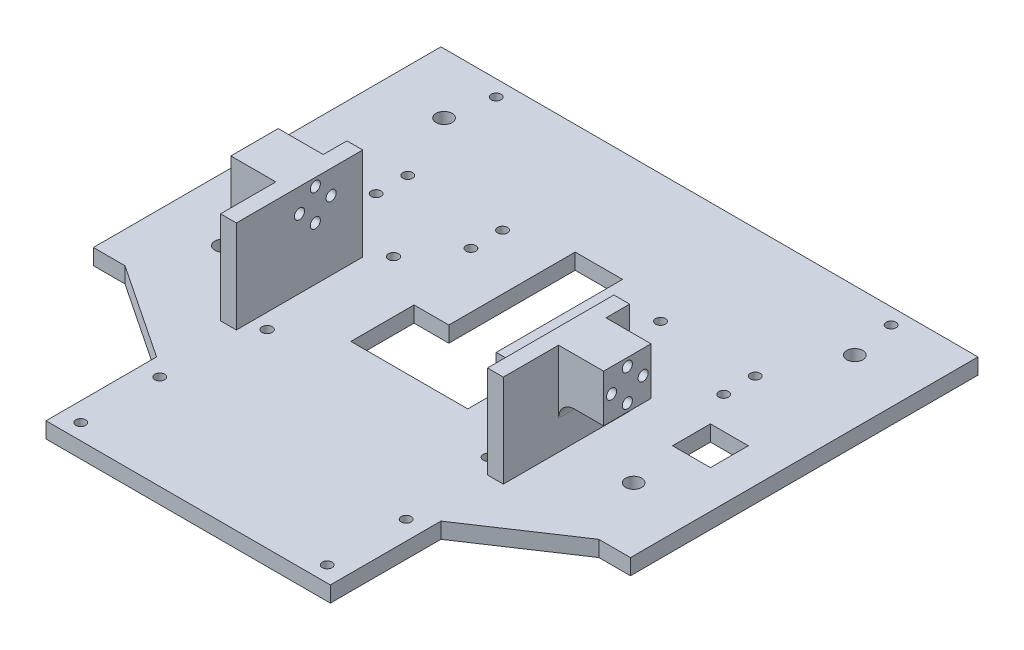
from build123d import *

# Parameters (mm, degrees)
BOSS_EXTRUDE1_DEPTH     = 5
CUT_EXTRUDE1_DEPTH      = 114.468057179
CUT_EXTRUDE1_DEPTH_BACK = 114.468057179
SKETCH3_R               = 1.6
SKETCH4_R               = 2.55
CUT_EXTRUDE2_DEPTH      = 10
SKETCH5_R               = 1.55
CUT_EXTRUDE3_DEPTH      = 114.468057179
SKETCH6_R               = 1.55
CUT_EXTRUDE4_DEPTH      = 114.468057179
SKETCH7_W               = 23
SKETCH7_H               = 110
BOSS_EXTRUDE2_DEPTH     = 5
SKETCH9_W               = 5
SKETCH9_H               = 40
BOSS_EXTRUDE4_DEPTH     = 33
SKETCH11_W              = 12
SKETCH11_H              = 12
CUT_EXTRUDE5_DEPTH      = 50
SKETCH12_R              = 1.6
CUT_EXTRUDE6_DEPTH      = 50
BOSS_EXTRUDE5_START     = 14.25
SKETCH13_W              = 15
SKETCH13_H              = 15
SKETCH13_R              = 1.6
BOSS_EXTRUDE5_DEPTH     = 14.25
SKETCH15_W              = 89.5
SKETCH15_H              = 3.65
CUT_EXTRUDE9_DEPTH      = 153.144667997
SKETCH18_W              = 13
SKETCH18_H              = 110
CUT_EXTRUDE10_DEPTH     = 134.005347637
FILLET5_R               = 5
SKETCH19_R              = 1.55
CUT_EXTRUDE11_DEPTH     = 5


with BuildPart() as part:
    # Sketch1 → Boss-Extrude1 (new body)
    with BuildSketch(Plane(origin=(0, 0, 0), x_dir=(1, 0, 0), z_dir=(0, 1, 0))):
        Polygon((75, 85), (-75, 85), (-75, -25), (-45, -45), (-45, -80), (45, -80), (45, -45), (75, -25), align=None)
        Polygon((-18.5, -10), (-18.5, 10), (-7.5, 10), (-7.5, 50), (7.5, 50), (7.5, 10), (18.5, 10), (18.5, -10), align=None, mode=Mode.SUBTRACT)
    extrude(amount=BOSS_EXTRUDE1_DEPTH)

    # Sketch3 → Cut-Extrude1 (cut, two sides: drawn at the far end of the back side and taken through both)
    with BuildSketch(Plane(origin=(0, 5, 0), x_dir=(1, 0, 0), z_dir=(0, 1, 0)).offset(-CUT_EXTRUDE1_DEPTH_BACK)):
        with Locations((-35, 20)):
            Circle(SKETCH3_R)
        with Locations((-35, -20)):
            Circle(SKETCH3_R)
        with Locations((35, -20)):
            Circle(SKETCH3_R)
        with Locations((35, 20)):
            Circle(SKETCH3_R)
    extrude(amount=CUT_EXTRUDE1_DEPTH + CUT_EXTRUDE1_DEPTH_BACK, mode=Mode.SUBTRACT)

    # Sketch4 → Cut-Extrude2 (cut)
    with BuildSketch(Plane(origin=(0, 5, 0), x_dir=(1, 0, 0), z_dir=(0, 1, 0))):
        with Locations((-65, 66)):
            Circle(SKETCH4_R)
        with Locations((-65, -4)):
            Circle(SKETCH4_R)
        with Locations((65, 66)):
            Circle(SKETCH4_R)
        with Locations((65, -4)):
            Circle(SKETCH4_R)
    extrude(amount=-CUT_EXTRUDE2_DEPTH, mode=Mode.SUBTRACT)

    # Sketch5 → Cut-Extrude3 (cut, through all)
    with BuildSketch(Plane(origin=(0, 5, 0), x_dir=(1, 0, 0), z_dir=(0, 1, 0))):
        with Locations((-39, -75)):
            Circle(SKETCH5_R)
        with Locations((39, -75)):
            Circle(SKETCH5_R)
        with Locations((-39, -50)):
            Circle(SKETCH5_R)
        with Locations((39, -50)):
            Circle(SKETCH5_R)
    extrude(amount=-CUT_EXTRUDE3_DEPTH, mode=Mode.SUBTRACT)

    # Sketch6 → Cut-Extrude4 (cut, through all)
    with BuildSketch(Plane(origin=(0, 5, 0), x_dir=(1, 0, 0), z_dir=(0, 1, 0))):
        with Locations((62.5, 80)):
            Circle(SKETCH6_R)
        with Locations((-62.5, 80)):
            Circle(SKETCH6_R)
    extrude(amount=-CUT_EXTRUDE4_DEPTH, mode=Mode.SUBTRACT)

    # Sketch7 → Boss-Extrude2 (add)
    with BuildSketch(Plane(origin=(0, 5, 0), x_dir=(1, 0, 0), z_dir=(0, 1, 0))):
        with Locations((-86.5, 30)):
            Rectangle(SKETCH7_W, SKETCH7_H)
        with Locations((86.5, 30)):
            Rectangle(SKETCH7_W, SKETCH7_H)
    extrude(amount=-BOSS_EXTRUDE2_DEPTH)

    # Sketch9 → Boss-Extrude4 (add)
    with BuildSketch(Plane(origin=(0, 5, 0), x_dir=(1, 0, 0), z_dir=(0, 1, 0))):
        with Locations((-42.25, -5)):
            Rectangle(SKETCH9_W, SKETCH9_H)
        with Locations((42.25, -5)):
            Rectangle(SKETCH9_W, SKETCH9_H)
    extrude(amount=BOSS_EXTRUDE4_DEPTH)

    # Sketch11 → Cut-Extrude5 (cut)
    with BuildSketch(Plane(origin=(0, 5, 0), x_dir=(1, 0, 0), z_dir=(0, 1, 0))):
        with Locations((-67, 18.305755671)):
            Rectangle(SKETCH11_W, SKETCH11_H)
        with Locations((67, 18.305755671)):
            Rectangle(SKETCH11_W, SKETCH11_H)
    extrude(amount=-CUT_EXTRUDE5_DEPTH, mode=Mode.SUBTRACT)

    # Sketch12 → Cut-Extrude6 (cut)
    with BuildSketch(Plane.ZY.offset(44.75)):
        with Locations((0, 31.85)):
            Circle(SKETCH12_R)
        with Locations((5, 26.85)):
            Circle(SKETCH12_R)
        with Locations((0, 21.85)):
            Circle(SKETCH12_R)
        with Locations((-5, 26.85)):
            Circle(SKETCH12_R)
    cut_extrude6 = extrude(amount=-CUT_EXTRUDE6_DEPTH, mode=Mode.SUBTRACT)

    # Sketch13 → Boss-Extrude5 (add)
    with BuildSketch(Plane.ZY.offset(44.75).offset(BOSS_EXTRUDE5_START)):
        with Locations((0, 26.85)):
            Rectangle(SKETCH13_W, SKETCH13_H)
        with Locations((0, 31.85)):
            Circle(SKETCH13_R, mode=Mode.SUBTRACT)
        with Locations((5, 26.85)):
            Circle(SKETCH13_R, mode=Mode.SUBTRACT)
        with Locations((-5, 26.85)):
            Circle(SKETCH13_R, mode=Mode.SUBTRACT)
        with Locations((0, 21.85)):
            Circle(SKETCH13_R, mode=Mode.SUBTRACT)
    boss_extrude5 = extrude(amount=-BOSS_EXTRUDE5_DEPTH)

    # Mirror2: Cut-Extrude6 across plane
    add(cut_extrude6.mirror(Plane.ZY), mode=Mode.SUBTRACT)

    # Mirror3: Boss-Extrude5 across plane
    add(boss_extrude5.mirror(Plane.ZY))

    # Sketch15 → Cut-Extrude9 (cut, through all)
    with BuildSketch(Plane.XY.offset(25)):
        with Locations((0, 36.175)):
            Rectangle(SKETCH15_W, SKETCH15_H)
    extrude(amount=-CUT_EXTRUDE9_DEPTH, mode=Mode.SUBTRACT)

    # Sketch18 → Cut-Extrude10 (cut, through all)
    with BuildSketch(Plane(origin=(0, 5, 0), x_dir=(1, 0, 0), z_dir=(0, 1, 0))):
        with Locations((-91.5, 30)):
            Rectangle(SKETCH18_W, SKETCH18_H)
        with Locations((91.5, 30)):
            Rectangle(SKETCH18_W, SKETCH18_H)
    extrude(amount=-CUT_EXTRUDE10_DEPTH, mode=Mode.SUBTRACT)

    # Fillet5
    fillet5_edges = [part.edges().sort_by_distance(p)[0] for p in [
        (44.75, 19.35, 0),
        (-44.75, 19.35, 0),
    ]]
    fillet(fillet5_edges, radius=FILLET5_R)

    # Sketch19 → Cut-Extrude11 (cut)
    with BuildSketch(Plane(origin=(0, 5, 0), x_dir=(1, 0, 0), z_dir=(0, 1, 0))):
        with Locations((55, 34.5)):
            Circle(SKETCH19_R)
        with Locations((25, 34.5)):
            Circle(SKETCH19_R)
        with Locations((25, 44.5)):
            Circle(SKETCH19_R)
        with Locations((55, 44.5)):
            Circle(SKETCH19_R)
    cut_extrude11 = extrude(amount=-CUT_EXTRUDE11_DEPTH, mode=Mode.SUBTRACT)

    # Mirror4: Cut-Extrude11 across plane
    add(cut_extrude11.mirror(Plane.ZY), mode=Mode.SUBTRACT)


solid = part.part
